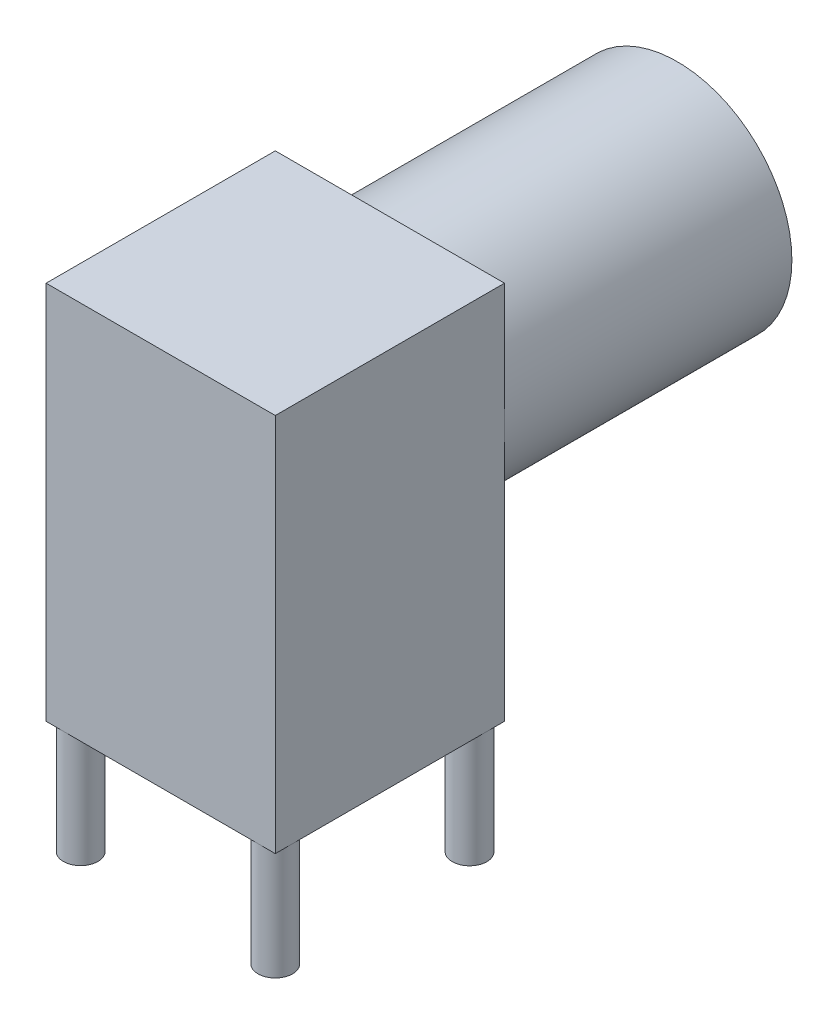
from build123d import *

# Parameters (mm, degrees)
SKETCH1_W           = 6.3
SKETCH1_H           = 6.3
BOSS_EXTRUDE1_DEPTH = 10.43
SKETCH2_R           = 3.15
BOSS_EXTRUDE2_DEPTH = 7.9
SKETCH3_R           = 0.475
BOSS_EXTRUDE3_DEPTH = 3.1


with BuildPart() as part:
    # Sketch1 → Boss-Extrude1 (new body)
    with BuildSketch(Plane(origin=(0, 0, 0), x_dir=(1, 0, 0), z_dir=(0, 1, 0))):
        Rectangle(SKETCH1_W, SKETCH1_H)
    extrude(amount=BOSS_EXTRUDE1_DEPTH)

    # Sketch2 → Boss-Extrude2 (add)
    with BuildSketch(Plane(origin=(0, 0, -3.15), x_dir=(-1, 0, 0), z_dir=(0, 0, -1))):
        with Locations((0, 7.029219023)):
            Circle(SKETCH2_R)
    extrude(amount=BOSS_EXTRUDE2_DEPTH)

    # Sketch3 → Boss-Extrude3 (add)
    with BuildSketch(Plane(origin=(0, 0, 0), x_dir=(-1, 0, 0), z_dir=(0, -1, 0))):
        Circle(SKETCH3_R)
        with Locations((2.675, -2.675)):
            Circle(SKETCH3_R)
        with Locations((-2.675, -2.675)):
            Circle(SKETCH3_R)
        with Locations((2.675, 2.66524354)):
            Circle(SKETCH3_R)
        with Locations((-2.675, 2.66524354)):
            Circle(SKETCH3_R)
    extrude(amount=BOSS_EXTRUDE3_DEPTH)


solid = part.part
